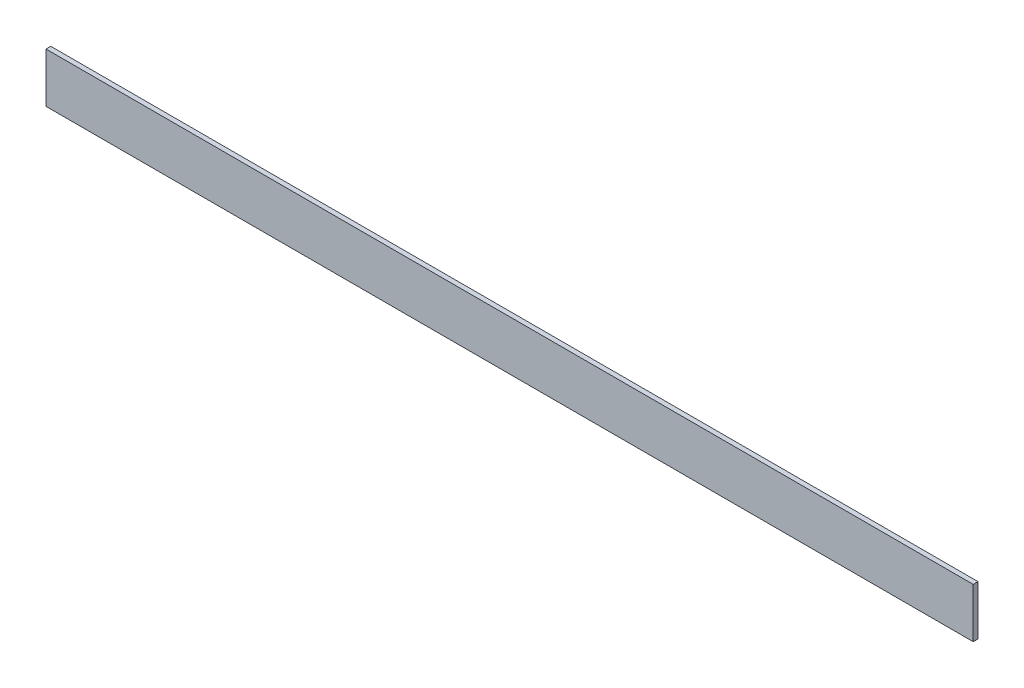
from build123d import *

# Parameters (mm, degrees)
SKETCH1_W           = 615.95
SKETCH1_H           = 33
BOSS_EXTRUDE1_DEPTH = 3.175


with BuildPart() as part:
    # Sketch1 → Boss-Extrude1 (new body)
    with BuildSketch(Plane.XY):
        with Locations((307.975, 16.5)):
            Rectangle(SKETCH1_W, SKETCH1_H)
    extrude(amount=BOSS_EXTRUDE1_DEPTH)


solid = part.part
